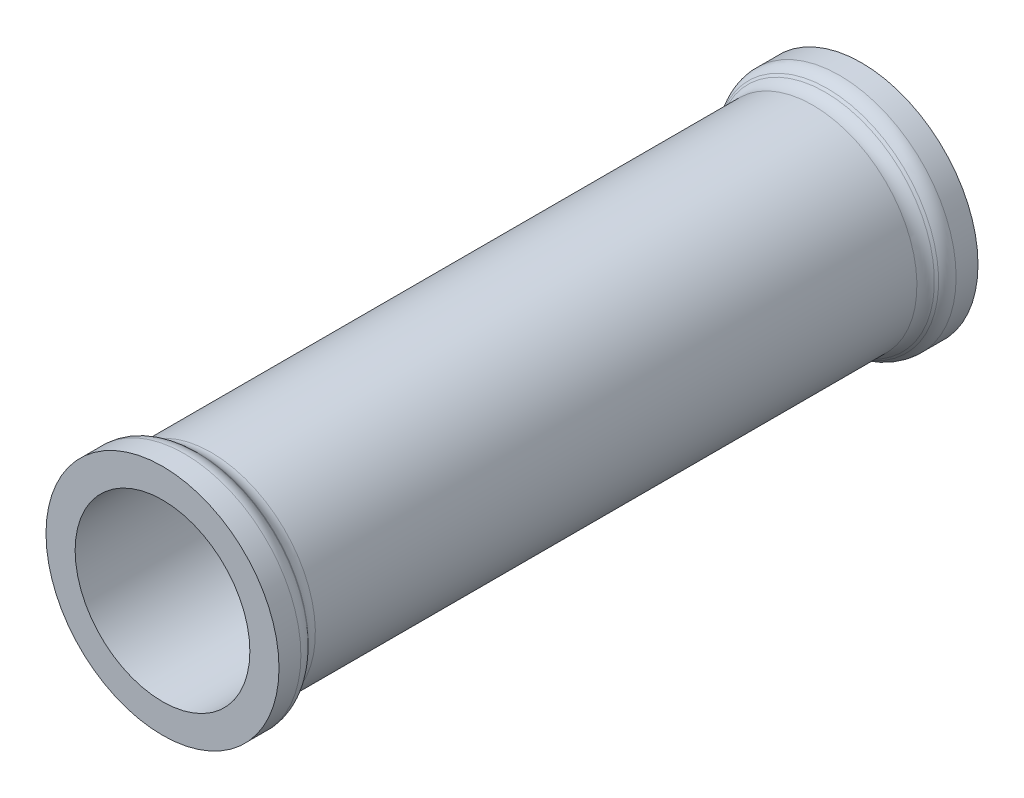
from build123d import *

# Parameters (mm, degrees)
SKETCH2_R          = 15
CUT_EXTRUDE1_DEPTH = 121


with BuildPart() as part:
    # Sketch1 → Revolve2 (revolve)
    with BuildSketch(Plane(origin=(0, 0, 0), x_dir=(0, 0, -1), z_dir=(1, 0, 0))):
        with BuildLine():
            Line((0, 0), (-120, 0))
            Line((-120, 0), (-120, -20))
            Line((-120, -20), (-116.242640687, -20))
            ThreePointArc((-116.242640687, -20), (-115.09459039, -19.771638598), (-114.121320344, -19.121320344))
            Line((-114.121320344, -19.121320344), (-113.757359313, -18.757359313))
            ThreePointArc((-113.757359313, -18.757359313), (-112.784089266, -18.107041059), (-111.636038969, -17.878679656))
            Line((-111.636038969, -17.878679656), (-8.363961031, -17.878679656))
            ThreePointArc((-8.363961031, -17.878679656), (-7.215910734, -18.107041059), (-6.242640687, -18.757359313))
            Line((-6.242640687, -18.757359313), (-5.878679656, -19.121320344))
            ThreePointArc((-5.878679656, -19.121320344), (-4.90540961, -19.771638598), (-3.757359313, -20))
            Line((-3.757359313, -20), (0, -20))
            Line((0, -20), (0, 0))
        make_face()
    revolve(axis=Axis((0, 0, 0), (0, 0, 1)))

    # Sketch2 → Cut-Extrude1 (cut, through all)
    with BuildSketch(Plane(origin=(0, 0, 0), x_dir=(-1, 0, 0), z_dir=(0, 0, -1))):
        Circle(SKETCH2_R)
    extrude(amount=-CUT_EXTRUDE1_DEPTH, mode=Mode.SUBTRACT)


solid = part.part
